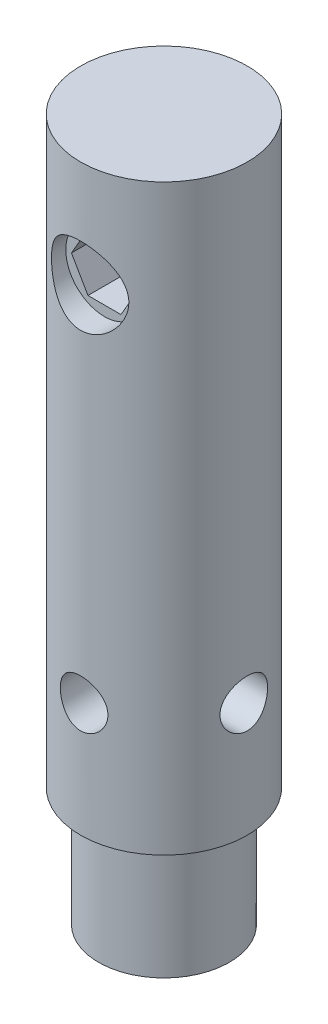
from build123d import *

# Parameters (mm, degrees)
SKETCH_1_R          = 14
EXTRUDE_1_DEPTH     = 98
SKETCH_2_R          = 6.5
SKETCH_2_R_2        = 4
CUT_EXTRUDE_1_DEPTH = 113.5
SKETCH_3_R          = 7.5
EXTRUDE_2_DEPTH     = 10
SKETCH_4_R          = 11
EXTRUDE_4_DEPTH     = 20
SKETCH_5_R          = 4
CUT_EXTRUDE_2_DEPTH = 20


with BuildPart() as part:
    # 草图1 → 凸台-拉伸1 (new body)
    with BuildSketch(Plane(origin=(0, 0, 0), x_dir=(1, 0, 0), z_dir=(0, 1, 0))):
        Circle(SKETCH_1_R)
    extrude(amount=EXTRUDE_1_DEPTH)

    # 草图2 → 切除-拉伸1 (cut, symmetric)
    with BuildSketch(Plane.XY):
        with Locations((0, 80)):
            Circle(SKETCH_2_R)
        with Locations((0, 19.2)):
            Circle(SKETCH_2_R_2)
    extrude(amount=CUT_EXTRUDE_1_DEPTH, both=True, mode=Mode.SUBTRACT)

    # 草图3 → 凸台-拉伸2 (add, symmetric)
    with BuildSketch(Plane.XY):
        with Locations((0, 80)):
            Circle(SKETCH_3_R)
        Polygon((5.55, 80), (2.775, 84.806440991), (-2.775, 84.806440991), (-5.55, 80), (-2.775, 75.193559009), (2.775, 75.193559009), align=None, mode=Mode.SUBTRACT)
    extrude(amount=EXTRUDE_2_DEPTH, both=True)

    # 草图4 → 凸台-拉伸4 (add)
    with BuildSketch(Plane.XZ):
        Circle(SKETCH_4_R)
    extrude(amount=EXTRUDE_4_DEPTH)

    # 草图5 → 切除-拉伸2 (cut, symmetric)
    with BuildSketch(Plane(origin=(0, 0, 0), x_dir=(0, 0, -1), z_dir=(1, 0, 0))):
        with Locations((0, 19.2)):
            Circle(SKETCH_5_R)
    extrude(amount=CUT_EXTRUDE_2_DEPTH, both=True, mode=Mode.SUBTRACT)


solid = part.part
